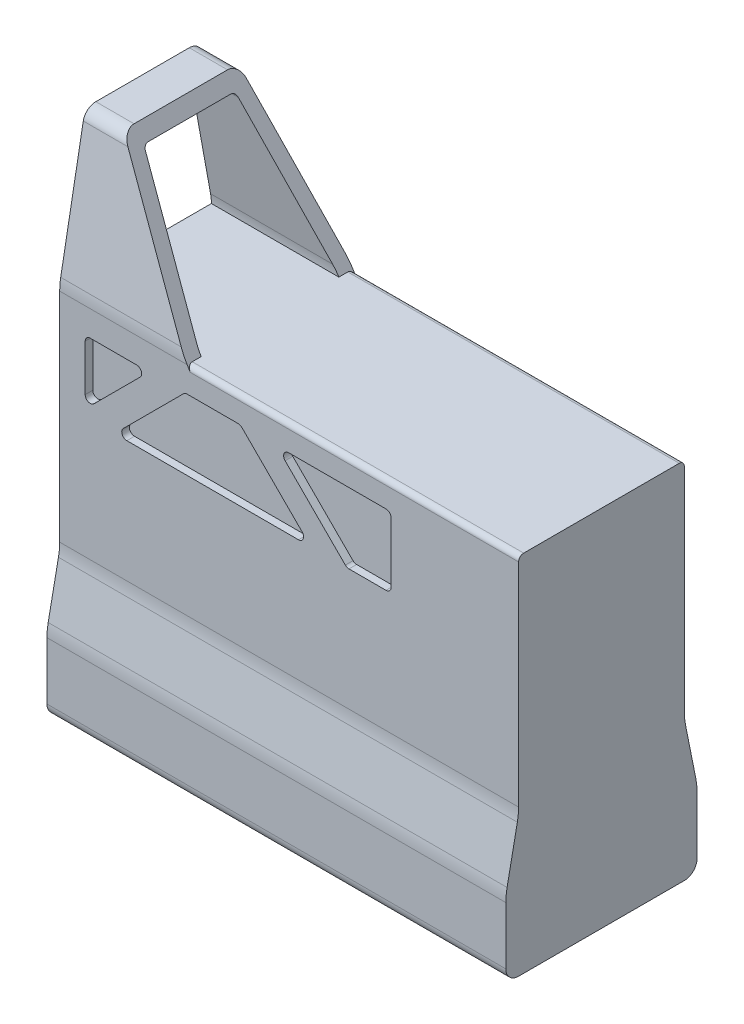
from build123d import *

# Parameters (mm, degrees)
EXTRUDE_2_DEPTH        = 140
SKETCH_7_W             = 65
SKETCH_7_H             = 74.928349175
CUT_EXTRUDE_2_DEPTH    = 150
CUT_EXTRUDE_3_DEPTH    = 150
FILLET_1_R             = 2
FILLET_2_R             = 2
CUT_EXTRUDE_4_DEPTH    = 3
FILLET_3_R             = 2
FILLET_3_OF_MIRROR_1_R = 2
EXTRUDE_3_DEPTH        = 40


with BuildPart() as part:
    # 草图2 → 凸台-拉伸2 (new body)
    with BuildSketch(Plane(origin=(0, 0, 0), x_dir=(0, 0, -1), z_dir=(1, 0, 0))):
        with BuildLine():
            Line((37.5, -95.110619623), (37.5, -72.586107463))
            ThreePointArc((37.5, -72.586107463), (37.378333167, -70.122667014), (37.014516892, -67.683204084))
            Line((37.014516892, -67.683204084), (32.985483108, -47.538035162))
            ThreePointArc((32.985483108, -47.538035162), (32.621666833, -45.098572232), (32.5, -42.635131783))
            Line((32.5, -42.635131783), (32.5, 42.635131783))
            ThreePointArc((32.5, 42.635131783), (32.398982849, 44.880271666), (32.096747752, 47.107267738))
            Line((32.096747752, 47.107267738), (23.246467783, 95.783807568))
            ThreePointArc((23.246467783, 95.783807568), (21.530855429, 98.728139028), (18.327118233, 99.889380377))
            Line((18.327118233, 99.889380377), (-18.327118233, 99.889380377))
            ThreePointArc((-18.327118233, 99.889380377), (-21.530855429, 98.728139028), (-23.246467783, 95.783807568))
            Line((-23.246467783, 95.783807568), (-32.096747752, 47.107267738))
            ThreePointArc((-32.096747752, 47.107267738), (-32.398982849, 44.880271666), (-32.5, 42.635131783))
            Line((-32.5, 42.635131783), (-32.5, -42.635131783))
            ThreePointArc((-32.5, -42.635131783), (-32.621666833, -45.098572232), (-32.985483108, -47.538035162))
            Line((-32.985483108, -47.538035162), (-37.014516892, -67.683204084))
            ThreePointArc((-37.014516892, -67.683204084), (-37.378333167, -70.122667014), (-37.5, -72.586107463))
            Line((-37.5, -72.586107463), (-37.5, -95.110619623))
            ThreePointArc((-37.5, -95.110619623), (-36.035533906, -98.646153529), (-32.5, -100.110619623))
            Line((-32.5, -100.110619623), (32.5, -100.110619623))
            ThreePointArc((32.5, -100.110619623), (36.035533906, -98.646153529), (37.5, -95.110619623))
        make_face()
    extrude(amount=EXTRUDE_2_DEPTH)

    # 草图7 → 切除-拉伸2 (cut, along a direction that is not the sketch's normal)
    with BuildSketch(Plane(origin=(55.371135265, 33.848837106, 0), x_dir=(0, 0, -1), z_dir=(0.853206949, 0.521572529, 0))):
        with Locations((0, 47.762138861)):
            Rectangle(SKETCH_7_W, SKETCH_7_H)
    extrude(amount=CUT_EXTRUDE_2_DEPTH, dir=(1, 0, 0), mode=Mode.SUBTRACT)

    # 草图8 → 切除-拉伸3 (cut)
    with BuildSketch(Plane.ZY):
        with BuildLine():
            Line((17.909830056, 94.389380377), (-17.909830056, 94.389380377))
            Line((-17.909830056, 94.389380377), (-26.685463247, 46.123397828))
            ThreePointArc((-26.685463247, 46.123397828), (-26.921206622, 44.386340892), (-27, 42.635131783))
            Line((-27, 42.635131783), (27, 42.635131783))
            ThreePointArc((27, 42.635131783), (26.921206622, 44.386340892), (26.685463247, 46.123397828))
            Line((26.685463247, 46.123397828), (17.909830056, 94.389380377))
        make_face()
    extrude(amount=-CUT_EXTRUDE_3_DEPTH, mode=Mode.SUBTRACT)

    # 圆角1
    fillet_1_edges = [part.edges().sort_by_distance(p)[0] for p in [
        (9.181097951, 94.389380377, 17.909830056),
        (9.181097951, 94.389380377, -17.909830056),
    ]]
    fillet(fillet_1_edges, radius=FILLET_1_R)

    # 圆角2
    fillet_2_edges = [part.edges().sort_by_distance(p)[0] for p in [
        (95, 42.635131783, 32.5),
        (95, 42.635131783, -32.5),
    ]]
    fillet(fillet_2_edges, radius=FILLET_2_R)

    # 草图9 → 切除-拉伸4 (cut)
    with BuildSketch(Plane(origin=(0, 0, -32.5), x_dir=(-1, 0, 0), z_dir=(0, 0, -1))):
        Polygon((-85, 32.635131783), (-130, 32.635131783), (-130, 5), (-112.635131783, 5), align=None)
        Polygon((-49.142135624, 32.635131783), (-70.857864376, 32.635131783), (-98.492996159, 5), (-21.507003841, 5), align=None)
        Polygon((-10, 32.635131783), (-35, 32.635131783), (-10, 7.635131783), align=None)
    cut_extrude_4 = extrude(amount=-CUT_EXTRUDE_4_DEPTH, mode=Mode.SUBTRACT)

    # 圆角3
    fillet_3_edges = [part.edges().sort_by_distance(p)[0] for p in [
        (21.507003841, 5, -31),
        (98.492996159, 5, -31),
        (70.857864376, 32.635131783, -31),
        (49.142135624, 32.635131783, -31),
        (35, 32.635131783, -31),
        (10, 32.635131783, -31),
        (10, 7.635131783, -31),
        (85, 32.635131783, -31),
        (112.635131783, 5, -31),
        (130, 5, -31),
        (130, 32.635131783, -31),
    ]]
    fillet(fillet_3_edges, radius=FILLET_3_R)

    # 镜向1: 切除-拉伸4 across plane
    add(cut_extrude_4.mirror(Plane.XY), mode=Mode.SUBTRACT)

    # 圆角3 of 镜向1
    fillet_3_of_mirror_1_edges = [part.edges().sort_by_distance(p)[0] for p in [
        (21.507003841, 5, 31),
        (98.492996159, 5, 31),
        (70.857864376, 32.635131783, 31),
        (49.142135624, 32.635131783, 31),
        (35, 32.635131783, 31),
        (10, 32.635131783, 31),
        (10, 7.635131783, 31),
        (85, 32.635131783, 31),
        (112.635131783, 5, 31),
        (130, 5, 31),
        (130, 32.635131783, 31),
    ]]
    fillet(fillet_3_of_mirror_1_edges, radius=FILLET_3_OF_MIRROR_1_R)

    # 草图10 → 凸台-拉伸3 (add)
    with BuildSketch(Plane(origin=(140, 0, 0), x_dir=(0, 0, -1), z_dir=(1, 0, 0))):
        with BuildLine():
            Line((32.5, -42.635131783), (32.5, 40.635131783))
            ThreePointArc((32.5, 40.635131783), (31.914213562, 42.049345346), (30.5, 42.635131783))
            Line((30.5, 42.635131783), (-30.5, 42.635131783))
            ThreePointArc((-30.5, 42.635131783), (-31.914213562, 42.049345346), (-32.5, 40.635131783))
            Line((-32.5, 40.635131783), (-32.5, -42.635131783))
            ThreePointArc((-32.5, -42.635131783), (-32.621666833, -45.098572232), (-32.985483108, -47.538035162))
            Line((-32.985483108, -47.538035162), (-37.014516892, -67.683204084))
            ThreePointArc((-37.014516892, -67.683204084), (-37.378333167, -70.122667014), (-37.5, -72.586107463))
            Line((-37.5, -72.586107463), (-37.5, -95.110619623))
            ThreePointArc((-37.5, -95.110619623), (-36.035533906, -98.646153529), (-32.5, -100.110619623))
            Line((-32.5, -100.110619623), (32.5, -100.110619623))
            ThreePointArc((32.5, -100.110619623), (36.035533906, -98.646153529), (37.5, -95.110619623))
            Line((37.5, -95.110619623), (37.5, -72.586107463))
            ThreePointArc((37.5, -72.586107463), (37.378333167, -70.122667014), (37.014516892, -67.683204084))
            Line((37.014516892, -67.683204084), (32.985483108, -47.538035162))
            ThreePointArc((32.985483108, -47.538035162), (32.621666833, -45.098572232), (32.5, -42.635131783))
        make_face()
    extrude(amount=EXTRUDE_3_DEPTH)


solid = part.part
